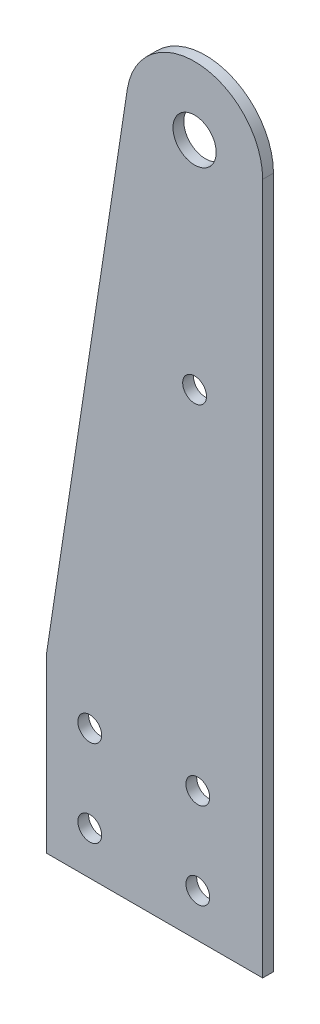
from build123d import *

# Parameters (mm, degrees)
SKETCH1_R           = 6.35
SKETCH1_R_2         = 3.5
BOSS_EXTRUDE1_DEPTH = 3.175


with BuildPart() as part:
    # Sketch1 → Boss-Extrude1 (new body)
    with BuildSketch(Plane.XY):
        with BuildLine():
            Line((-31.75, -25.4), (31.75, -25.4))
            Line((31.75, -25.4), (31.75, 177.8))
            ThreePointArc((31.75, 177.8), (13.263638058, 197.742640242), (-8.020889983, 180.818593926))
            Line((-8.020889983, 180.818593926), (-31.75, 25.4))
            Line((-31.75, 25.4), (-31.75, -25.4))
        make_face()
        with Locations((11.75, 177.8)):
            Circle(SKETCH1_R, mode=Mode.SUBTRACT)
        with Locations((-19.05, 12.7)):
            Circle(SKETCH1_R_2, mode=Mode.SUBTRACT)
        with Locations((12.7, 12.7)):
            Circle(SKETCH1_R_2, mode=Mode.SUBTRACT)
        with Locations((12.7, -12.7)):
            Circle(SKETCH1_R_2, mode=Mode.SUBTRACT)
        with Locations((-19.05, -12.7)):
            Circle(SKETCH1_R_2, mode=Mode.SUBTRACT)
        with Locations((11.75, 114.3)):
            Circle(SKETCH1_R_2, mode=Mode.SUBTRACT)
    extrude(amount=BOSS_EXTRUDE1_DEPTH)


solid = part.part
